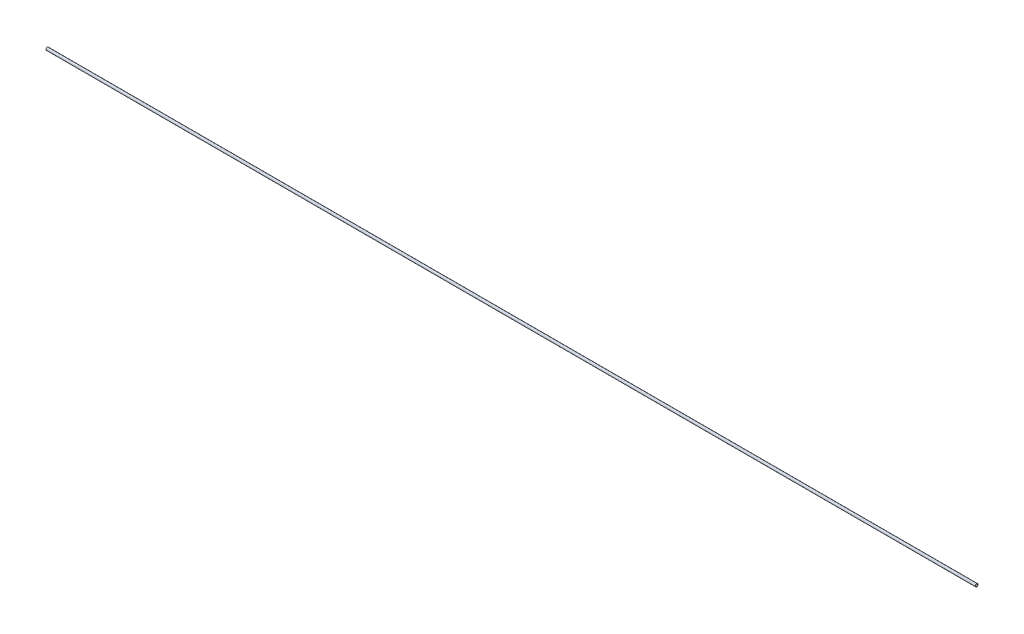
from build123d import *

# Parameters (mm, degrees)
SKETCH1_R           = 2.38125
SKETCH1_R_2         = 1.82245
BOSS_EXTRUDE1_DEPTH = 1651


with BuildPart() as part:
    # Sketch1 → Boss-Extrude1 (new body)
    with BuildSketch(Plane(origin=(0, 0, 0), x_dir=(0, 0, -1), z_dir=(1, 0, 0))):
        Circle(SKETCH1_R)
        Circle(SKETCH1_R_2, mode=Mode.SUBTRACT)
    extrude(amount=BOSS_EXTRUDE1_DEPTH)


solid = part.part
